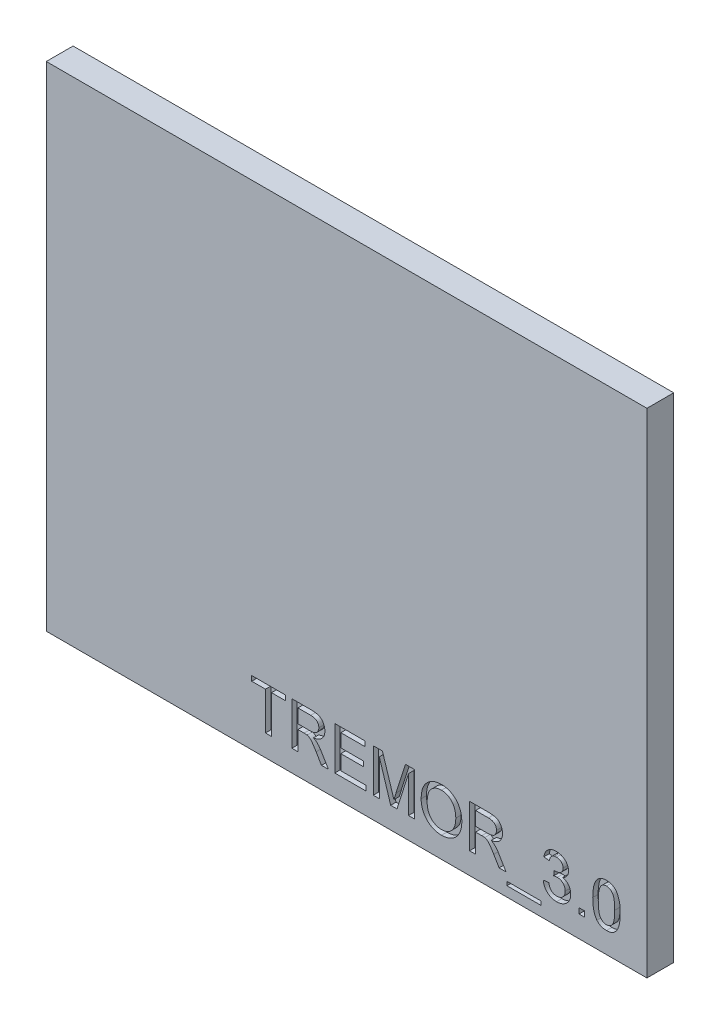
from build123d import *

# Parameters (mm, degrees)
SKETCH_1_W          = 56
SKETCH_1_H          = 46
EXTRUDE_2_DEPTH     = 2.5
SKETCH_3_W          = 3.179487179
SKETCH_3_H          = 0.358974359
SKETCH_3_W_2        = 0.512820512
SKETCH_3_H_2        = 0.512820513
CUT_EXTRUDE_2_DEPTH = 0.5


with BuildPart() as part:
    # Эскиз1 → Бобышка-Вытянуть2 (new body)
    with BuildSketch(Plane.XY):
        Rectangle(SKETCH_1_W, SKETCH_1_H)
    extrude(amount=EXTRUDE_2_DEPTH)

    # Эскиз3 → Вырез-Вытянуть2 (cut)
    with BuildSketch(Plane.XY.offset(2.5)):
        Polygon((-7.564102564, -21), (-7.564102564, -17.461538462), (-8.846153846, -17.461538462), (-8.846153846, -17), (-5.717948718, -17), (-5.717948718, -17.461538462), (-7, -17.461538462), (-7, -21), align=None)
        with BuildLine():
            Line((-5.102564103, -21), (-5.102564103, -17))
            Line((-5.102564103, -17), (-3.366987179, -17))
            add(Edge.make_bspline(
                [(-3.366987179, -17), (-3.326119657, -17.000320214), (-3.247025351, -17.000939951), (-3.132322277, -17.005326982), (-3.025258455, -17.014784271), (-2.925637033, -17.025011011), (-2.833475709, -17.040707691), (-2.748869564, -17.058711428), (-2.67168797, -17.080136147), (-2.60158588, -17.105440392), (-2.536546426, -17.134068355), (-2.476259765, -17.169390639), (-2.418219858, -17.208096331), (-2.364580768, -17.253569742), (-2.31392776, -17.303358919), (-2.26630778, -17.358140389), (-2.222425804, -17.418389546), (-2.168302642, -17.504618584), (-2.110239523, -17.619457505), (-2.061863826, -17.76642644), (-2.030672041, -17.92016131), (-2.027334431, -18.025221285), (-2.025641026, -18.078525641)],
                knots=[0, 0, 0, 0, 0.000122607, 0.000237291, 0.000344225, 0.000445012, 0.000537618, 0.00062453, 0.000704438, 0.000777688, 0.000847982, 0.000917255, 0.00098704, 0.001057009, 0.001127835, 0.001199973, 0.001274496, 0.001351194, 0.001505282, 0.001659088, 0.001814192, 0.001973937, 0.001973937, 0.001973937, 0.001973937], degree=3))
            add(Edge.make_bspline(
                [(-2.025641026, -18.078525641), (-2.026423756, -18.112742284), (-2.027969703, -18.1803225), (-2.039811808, -18.279683507), (-2.061239141, -18.374618953), (-2.088715472, -18.465960267), (-2.126322187, -18.552413288), (-2.169887935, -18.635743845), (-2.223859702, -18.713662625), (-2.284287063, -18.788244481), (-2.353581043, -18.857892068), (-2.432351217, -18.920092674), (-2.519816756, -18.976042242), (-2.616389588, -19.024197105), (-2.720958061, -19.068212935), (-2.834834224, -19.103656602), (-2.95755848, -19.132599074), (-3.04263664, -19.146614136), (-3.086538462, -19.153846154)],
                knots=[0, 0, 0, 0, 0.000102642, 0.000202726, 0.000299545, 0.000394334, 0.000488395, 0.000581956, 0.000675966, 0.000772203, 0.000869657, 0.000970019, 0.001072711, 0.001180575, 0.001293371, 0.00141273, 0.001537894, 0.001671343, 0.001671343, 0.001671343, 0.001671343], degree=3))
            add(Edge.make_bspline(
                [(-3.086538462, -19.153846154), (-3.054334812, -19.170114727), (-2.993178922, -19.201009334), (-2.908507834, -19.249451809), (-2.836735085, -19.298948081), (-2.795153494, -19.33434927), (-2.775641026, -19.350961538)],
                knots=[0, 0, 0, 0, 0.000108229, 0.000205532, 0.000292444, 0.000369288, 0.000369288, 0.000369288, 0.000369288], degree=3))
            add(Edge.make_bspline(
                [(-2.775641026, -19.350961538), (-2.737854029, -19.388003838), (-2.660236854, -19.464091352), (-2.553277014, -19.593690678), (-2.449575777, -19.737954614), (-2.386569456, -19.842214649), (-2.354166667, -19.895833333)],
                knots=[0, 0, 0, 0, 0.00015865, 0.000325878, 0.000503323, 0.000691201, 0.000691201, 0.000691201, 0.000691201], degree=3))
            Line((-2.354166667, -19.895833333), (-1.697916667, -21))
            Line((-1.697916667, -21), (-2.344551282, -21))
            Line((-2.344551282, -21), (-2.842948718, -20.155448718))
            add(Edge.make_bspline(
                [(-2.842948718, -20.155448718), (-2.860868586, -20.125816621), (-2.895594349, -20.068394483), (-2.945754469, -19.984532214), (-2.994934817, -19.907323634), (-3.040548749, -19.834562079), (-3.084447354, -19.767568499), (-3.126206469, -19.706110171), (-3.164676865, -19.649380844), (-3.212327424, -19.583333143), (-3.26778476, -19.510250749), (-3.332499667, -19.434989684), (-3.394127445, -19.374985039), (-3.470023191, -19.316144102), (-3.564031555, -19.261108296), (-3.643940439, -19.235820855), (-3.682692308, -19.223557692)],
                knots=[0, 0, 0, 0, 0.000103889, 0.00020132, 0.000293136, 0.000378497, 0.00045895, 0.0005334, 0.00060141, 0.000664564, 0.000777712, 0.000876533, 0.000962106, 0.001035194, 0.001164397, 0.001286049, 0.001286049, 0.001286049, 0.001286049], degree=3))
            add(Edge.make_bspline(
                [(-3.682692308, -19.223557692), (-3.698951156, -19.220625669), (-3.736070593, -19.213931773), (-3.799099306, -19.209559979), (-3.875466323, -19.204919904), (-3.930810802, -19.205055101), (-3.960737179, -19.205128205)],
                knots=[0, 0, 0, 0, 4.9531e-05, 0.00011308, 0.000189307, 0.000279054, 0.000279054, 0.000279054, 0.000279054], degree=3))
            Line((-3.960737179, -19.205128205), (-4.538461538, -19.205128205))
            Line((-4.538461538, -19.205128205), (-4.538461538, -21))
            Line((-4.538461538, -21), (-5.102564103, -21))
        make_face()
        with BuildLine():
            Line((-4.538461538, -18.743589744), (-3.467147436, -18.743589744))
            add(Edge.make_bspline(
                [(-3.467147436, -18.743589744), (-3.413427689, -18.742749247), (-3.31300366, -18.741178018), (-3.172576543, -18.727761372), (-3.052901394, -18.706441753), (-2.951612407, -18.675344591), (-2.86651367, -18.632171403), (-2.792501681, -18.579556806), (-2.730996786, -18.513651547), (-2.679831068, -18.439291493), (-2.640058905, -18.357461965), (-2.611369163, -18.271512044), (-2.592591229, -18.182164082), (-2.59070121, -18.121355097), (-2.58974359, -18.090544872)],
                knots=[0, 0, 0, 0, 0.000161129, 0.000301216, 0.000422697, 0.000525327, 0.00061778, 0.000707856, 0.000796274, 0.000886733, 0.000977756, 0.001068215, 0.001158102, 0.00125042, 0.00125042, 0.00125042, 0.00125042], degree=3))
            add(Edge.make_bspline(
                [(-2.58974359, -18.090544872), (-2.590488099, -18.068092289), (-2.591946375, -18.024114276), (-2.599591139, -17.959566763), (-2.614454374, -17.898231705), (-2.63408124, -17.83978488), (-2.660306715, -17.784654368), (-2.69146151, -17.732412969), (-2.728638798, -17.683350225), (-2.771223243, -17.637316685), (-2.820117924, -17.595430661), (-2.875967144, -17.559292108), (-2.938330425, -17.528582134), (-3.007280253, -17.504208646), (-3.082599423, -17.484713823), (-3.164716712, -17.471744546), (-3.253256579, -17.46236002), (-3.314609572, -17.461817431), (-3.346153846, -17.461538462)],
                knots=[0, 0, 0, 0, 6.7384e-05, 0.000131985, 0.000194568, 0.000256396, 0.000316615, 0.000377354, 0.000438572, 0.000500939, 0.000565166, 0.000631174, 0.000699977, 0.000773227, 0.000850188, 0.000933046, 0.001022424, 0.001117006, 0.001117006, 0.001117006, 0.001117006], degree=3))
            Line((-3.346153846, -17.461538462), (-4.538461538, -17.461538462))
            Line((-4.538461538, -17.461538462), (-4.538461538, -18.743589744))
        make_face(mode=Mode.SUBTRACT)
        Polygon((-1.102564103, -21), (-1.102564103, -17), (1.717948718, -17), (1.717948718, -17.461538462), (-0.538461538, -17.461538462), (-0.538461538, -18.692307692), (1.564102564, -18.692307692), (1.564102564, -19.153846154), (-0.538461538, -19.153846154), (-0.538461538, -20.538461538), (1.820512821, -20.538461538), (1.820512821, -21), align=None)
        with BuildLine():
            Line((2.487179487, -21), (2.487179487, -17))
            Line((2.487179487, -17), (3.335737179, -17))
            Line((3.335737179, -17), (4.229967949, -19.806891026))
            add(Edge.make_bspline(
                [(4.229967949, -19.806891026), (4.239808996, -19.838688209), (4.25884101, -19.900182111), (4.287063227, -19.988984965), (4.312740714, -20.071507311), (4.335867334, -20.148011825), (4.357692224, -20.218118663), (4.37658914, -20.282403106), (4.394655207, -20.340150808), (4.405242729, -20.376851361), (4.41025641, -20.394230769)],
                knots=[0, 0, 0, 0, 9.9855e-05, 0.000193114, 0.000279538, 0.000359127, 0.000432884, 0.000499809, 0.000560135, 0.000614398, 0.000614398, 0.000614398, 0.000614398], degree=3))
            add(Edge.make_bspline(
                [(4.41025641, -20.394230769), (4.415840487, -20.375259626), (4.427723758, -20.33488782), (4.446988442, -20.271410075), (4.467486613, -20.201164808), (4.492016641, -20.125359419), (4.517586292, -20.042804761), (4.544424968, -19.953569392), (4.575382859, -19.858544221), (4.595955924, -19.792756834), (4.606570513, -19.758814103)],
                knots=[0, 0, 0, 0, 5.9327e-05, 0.000126252, 0.00019901, 0.000278838, 0.000365261, 0.000458282, 0.000558378, 0.000665069, 0.000665069, 0.000665069, 0.000665069], degree=3))
            Line((4.606570513, -19.758814103), (5.491987179, -17))
            Line((5.491987179, -17), (6.333333333, -17))
            Line((6.333333333, -17), (6.333333333, -21))
            Line((6.333333333, -21), (5.769230769, -21))
            Line((5.769230769, -21), (5.769230769, -17.615384615))
            Line((5.769230769, -17.615384615), (4.701923077, -21))
            Line((4.701923077, -21), (4.112179487, -21))
            Line((4.112179487, -21), (3.051282051, -17.615384615))
            Line((3.051282051, -17.615384615), (3.051282051, -21))
            Line((3.051282051, -21), (2.487179487, -21))
        make_face()
        with BuildLine():
            add(Edge.make_bspline(
                [(6.948717949, -19.052884615), (6.950108195, -18.972688063), (6.952817019, -18.816429148), (6.978127021, -18.588896033), (7.019223968, -18.374817135), (7.077975691, -18.174209132), (7.152443668, -17.98675767), (7.242973719, -17.812038293), (7.35228893, -17.6520287), (7.475952289, -17.505205703), (7.614078581, -17.375403412), (7.761143824, -17.260120381), (7.918984399, -17.163960703), (8.086141982, -17.084564511), (8.263326754, -17.023606414), (8.450041232, -16.980930199), (8.646085728, -16.953399893), (8.780086729, -16.950301265), (8.848557692, -16.948717949)],
                knots=[0, 0, 0, 0, 0.000240518, 0.000468637, 0.000685813, 0.00089373, 0.001094751, 0.001290081, 0.001482766, 0.00167493, 0.001864807, 0.002050409, 0.002234557, 0.002418072, 0.002604576, 0.002795443, 0.002991942, 0.003197259, 0.003197259, 0.003197259, 0.003197259], degree=3))
            add(Edge.make_bspline(
                [(8.848557692, -16.948717949), (8.893718998, -16.94950655), (8.983401183, -16.95107257), (9.115988289, -16.962987889), (9.245168372, -16.984254669), (9.370814224, -17.01275454), (9.493267851, -17.050145131), (9.612602383, -17.094283586), (9.727773177, -17.148977346), (9.839546435, -17.210212454), (9.946602755, -17.278706569), (10.047214018, -17.35437188), (10.141139226, -17.436636132), (10.22964005, -17.524147125), (10.309763341, -17.619858234), (10.384819198, -17.720853933), (10.452650846, -17.828925041), (10.513498966, -17.943186098), (10.567903369, -18.061872362), (10.614402437, -18.18547574), (10.654330338, -18.312513522), (10.68775336, -18.443737637), (10.71173528, -18.579103224), (10.730832342, -18.718027005), (10.740883654, -18.86096303), (10.742680104, -18.957518861), (10.743589744, -19.006410256)],
                knots=[0, 0, 0, 0, 0.000135476, 0.000269031, 0.000398917, 0.000527984, 0.000655234, 0.000782779, 0.000909315, 0.001037342, 0.001164925, 0.001290246, 0.00141462, 0.00153927, 0.001663208, 0.001788692, 0.001916521, 0.002045575, 0.002176811, 0.002307921, 0.002441476, 0.002576153, 0.002713829, 0.00285367, 0.002996679, 0.003143368, 0.003143368, 0.003143368, 0.003143368], degree=3))
            add(Edge.make_bspline(
                [(10.743589744, -19.006410256), (10.742756316, -19.056107872), (10.741109736, -19.15429408), (10.729968302, -19.29934515), (10.710377788, -19.440232105), (10.684394308, -19.577375043), (10.649577237, -19.710488463), (10.608202498, -19.839954008), (10.558157415, -19.965000556), (10.501637049, -20.085929494), (10.437684279, -20.201077631), (10.367140035, -20.309639796), (10.289954339, -20.410600475), (10.207299635, -20.505198199), (10.117245715, -20.591741383), (10.020901471, -20.67103927), (9.918637345, -20.743839729), (9.810109783, -20.808171096), (9.697266459, -20.864559837), (9.582340364, -20.914586809), (9.46524613, -20.957251802), (9.345583564, -20.991827538), (9.223679094, -21.017955452), (9.099875772, -21.03752031), (8.973767756, -21.048785823), (8.888910404, -21.050445699), (8.846153846, -21.051282051)],
                knots=[0, 0, 0, 0, 0.000149092, 0.000294558, 0.000436094, 0.000575642, 0.000713045, 0.000848613, 0.000983123, 0.001116825, 0.00124882, 0.001377946, 0.001504873, 0.001629775, 0.001754446, 0.001879099, 0.002003823, 0.002130662, 0.002257158, 0.002382047, 0.002506504, 0.002630767, 0.0027554, 0.002880287, 0.003006587, 0.003134855, 0.003134855, 0.003134855, 0.003134855], degree=3))
            add(Edge.make_bspline(
                [(8.846153846, -21.051282051), (8.800181051, -21.050601878), (8.709120456, -21.049254625), (8.574530444, -21.035806746), (8.443288821, -21.015291538), (8.315777128, -20.985673775), (8.192169605, -20.947035311), (8.072319997, -20.900268536), (7.95580678, -20.845998474), (7.844075689, -20.782671197), (7.737507013, -20.712258071), (7.637133652, -20.635109117), (7.54301111, -20.551935333), (7.456649669, -20.461361953), (7.375252352, -20.366672299), (7.302073791, -20.264346815), (7.234724088, -20.156706135), (7.17519623, -20.04271265), (7.12142172, -19.925753814), (7.076115533, -19.805792216), (7.036300175, -19.68459577), (7.004591274, -19.561417471), (6.979323137, -19.436541465), (6.962332147, -19.310175541), (6.950061124, -19.182131498), (6.949167927, -19.096183714), (6.948717949, -19.052884615)],
                knots=[0, 0, 0, 0, 0.000137879, 0.000273103, 0.000405363, 0.000536171, 0.000665424, 0.000793541, 0.000921869, 0.001050676, 0.001178462, 0.001304753, 0.001430186, 0.001554857, 0.001679924, 0.001804463, 0.001931867, 0.002060544, 0.002189991, 0.00231782, 0.002445024, 0.002572516, 0.002699174, 0.002826998, 0.002954895, 0.003084742, 0.003084742, 0.003084742, 0.003084742], degree=3))
        make_face()
        with BuildLine():
            add(Edge.make_bspline(
                [(7.512820513, -19.059294872), (7.513684973, -19.117043625), (7.51537061, -19.229649619), (7.534655208, -19.39382317), (7.563916506, -19.548729276), (7.604250116, -19.694802796), (7.658468365, -19.830599083), (7.723293301, -19.95742301), (7.800907597, -20.074431521), (7.889598848, -20.181297299), (7.987149056, -20.277297507), (8.091391354, -20.361148581), (8.202349174, -20.431367925), (8.318792352, -20.489348983), (8.441557244, -20.534608486), (8.570276169, -20.566388569), (8.705043701, -20.58626443), (8.796938538, -20.588569422), (8.84375, -20.58974359)],
                knots=[0, 0, 0, 0, 0.000173168, 0.000337665, 0.000495129, 0.000645808, 0.000791478, 0.000933036, 0.001072378, 0.001211803, 0.001348923, 0.001482322, 0.001612362, 0.001742083, 0.001871881, 0.002004032, 0.00213922, 0.002279591, 0.002279591, 0.002279591, 0.002279591], degree=3))
            add(Edge.make_bspline(
                [(8.84375, -20.58974359), (8.891354918, -20.588552055), (8.984565213, -20.586219033), (9.121364549, -20.56669014), (9.251339232, -20.533443034), (9.375777543, -20.489183603), (9.492429758, -20.429352398), (9.604024039, -20.359290384), (9.707518311, -20.27367661), (9.805453067, -20.177506616), (9.893293946, -20.068191756), (9.971234233, -19.948424801), (10.034547437, -19.816409553), (10.089209843, -19.675054127), (10.129236807, -19.521686851), (10.158819186, -19.358051203), (10.176646155, -19.183620818), (10.178523426, -19.063877596), (10.179487179, -19.002403846)],
                knots=[0, 0, 0, 0, 0.000142772, 0.000279548, 0.000413448, 0.000544751, 0.00067483, 0.000805976, 0.000939254, 0.001076937, 0.001217095, 0.001359121, 0.001504613, 0.001655512, 0.001813144, 0.001979273, 0.002154042, 0.002338423, 0.002338423, 0.002338423, 0.002338423], degree=3))
            add(Edge.make_bspline(
                [(10.179487179, -19.002403846), (10.179146589, -18.962855637), (10.178478475, -18.885276363), (10.169630401, -18.770923625), (10.158217521, -18.660127911), (10.140841233, -18.553032189), (10.116894504, -18.450079966), (10.090365595, -18.350487464), (10.057192122, -18.255112917), (10.019552193, -18.163582302), (9.97743375, -18.07636552), (9.929929749, -17.994197843), (9.877592282, -17.917398722), (9.821833476, -17.844512122), (9.759565724, -17.778359053), (9.693787254, -17.716145179), (9.623003911, -17.659155853), (9.547922087, -17.607376188), (9.469606915, -17.560766328), (9.388219841, -17.520874336), (9.305057476, -17.485834233), (9.218727802, -17.458974524), (9.130422863, -17.437311773), (9.039785685, -17.420856897), (8.946479846, -17.412335797), (8.883561888, -17.410954516), (8.851762821, -17.41025641)],
                knots=[0, 0, 0, 0, 0.000118614, 0.000232678, 0.000343906, 0.000452715, 0.000557879, 0.000660905, 0.000761759, 0.000860564, 0.000957681, 0.0010521, 0.001144996, 0.001236357, 0.001327075, 0.001417208, 0.001507809, 0.001599384, 0.001690631, 0.001780935, 0.00187111, 0.001961072, 0.002051829, 0.002143781, 0.002237147, 0.002332553, 0.002332553, 0.002332553, 0.002332553], degree=3))
            add(Edge.make_bspline(
                [(8.851762821, -17.41025641), (8.806819177, -17.411148973), (8.718140361, -17.4129101), (8.587594586, -17.432487753), (8.461734305, -17.461739442), (8.340364196, -17.502634862), (8.224522319, -17.556786824), (8.113608506, -17.623196796), (8.006638236, -17.700056537), (7.905298277, -17.789238719), (7.810827268, -17.891687275), (7.730961508, -18.012470984), (7.663648464, -18.148706484), (7.607443312, -18.30004845), (7.564588538, -18.467668926), (7.53497053, -18.650846562), (7.516270323, -18.849774382), (7.513999848, -18.987669243), (7.512820513, -19.059294872)],
                knots=[0, 0, 0, 0, 0.000134732, 0.000265842, 0.000395089, 0.000522039, 0.000649301, 0.000777926, 0.000909359, 0.00104391, 0.001182325, 0.001326112, 0.001476617, 0.001637361, 0.001809553, 0.001994765, 0.002193538, 0.002408378, 0.002408378, 0.002408378, 0.002408378], degree=3))
        make_face(mode=Mode.SUBTRACT)
        with BuildLine():
            Line((11.461538462, -21), (11.461538462, -17))
            Line((11.461538462, -17), (13.197115385, -17))
            add(Edge.make_bspline(
                [(13.197115385, -17), (13.237982907, -17.000320214), (13.317077213, -17.000939951), (13.431780288, -17.005326982), (13.538844109, -17.014784271), (13.638465531, -17.025011011), (13.730626855, -17.040707691), (13.815233, -17.058711428), (13.892414594, -17.080136147), (13.962516684, -17.105440392), (14.027556138, -17.134068355), (14.087842799, -17.169390639), (14.145882706, -17.208096331), (14.199521796, -17.253569742), (14.250174804, -17.303358919), (14.297794784, -17.358140389), (14.34167676, -17.418389546), (14.395799922, -17.504618584), (14.453863041, -17.619457505), (14.502238738, -17.76642644), (14.533430523, -17.92016131), (14.536768133, -18.025221285), (14.538461538, -18.078525641)],
                knots=[0, 0, 0, 0, 0.000122607, 0.000237291, 0.000344225, 0.000445012, 0.000537618, 0.00062453, 0.000704438, 0.000777688, 0.000847982, 0.000917255, 0.00098704, 0.001057009, 0.001127835, 0.001199973, 0.001274496, 0.001351194, 0.001505282, 0.001659088, 0.001814192, 0.001973937, 0.001973937, 0.001973937, 0.001973937], degree=3))
            add(Edge.make_bspline(
                [(14.538461538, -18.078525641), (14.537678808, -18.112742284), (14.536132862, -18.1803225), (14.524290756, -18.279683507), (14.502863423, -18.374618953), (14.475387092, -18.465960267), (14.437780377, -18.552413288), (14.394214629, -18.635743845), (14.340242862, -18.713662625), (14.279815501, -18.788244481), (14.210521522, -18.857892068), (14.131751347, -18.920092674), (14.044285808, -18.976042242), (13.947712976, -19.024197105), (13.843144503, -19.068212935), (13.72926834, -19.103656602), (13.606544084, -19.132599074), (13.521465925, -19.146614136), (13.477564103, -19.153846154)],
                knots=[0, 0, 0, 0, 0.000102642, 0.000202726, 0.000299545, 0.000394334, 0.000488395, 0.000581956, 0.000675966, 0.000772203, 0.000869657, 0.000970019, 0.001072711, 0.001180575, 0.001293371, 0.00141273, 0.001537894, 0.001671343, 0.001671343, 0.001671343, 0.001671343], degree=3))
            add(Edge.make_bspline(
                [(13.477564103, -19.153846154), (13.509767752, -19.170114727), (13.570923642, -19.201009334), (13.65559473, -19.249451809), (13.72736748, -19.298948081), (13.768949071, -19.33434927), (13.788461538, -19.350961538)],
                knots=[0, 0, 0, 0, 0.000108229, 0.000205532, 0.000292444, 0.000369288, 0.000369288, 0.000369288, 0.000369288], degree=3))
            add(Edge.make_bspline(
                [(13.788461538, -19.350961538), (13.826248535, -19.388003838), (13.90386571, -19.464091352), (14.01082555, -19.593690678), (14.114526787, -19.737954614), (14.177533108, -19.842214649), (14.209935897, -19.895833333)],
                knots=[0, 0, 0, 0, 0.00015865, 0.000325878, 0.000503323, 0.000691201, 0.000691201, 0.000691201, 0.000691201], degree=3))
            Line((14.209935897, -19.895833333), (14.866185897, -21))
            Line((14.866185897, -21), (14.219551282, -21))
            Line((14.219551282, -21), (13.721153846, -20.155448718))
            add(Edge.make_bspline(
                [(13.721153846, -20.155448718), (13.703233978, -20.125816621), (13.668508215, -20.068394483), (13.618348095, -19.984532214), (13.569167747, -19.907323634), (13.523553815, -19.834562079), (13.47965521, -19.767568499), (13.437896095, -19.706110171), (13.399425699, -19.649380844), (13.35177514, -19.583333143), (13.296317804, -19.510250749), (13.231602897, -19.434989684), (13.169975119, -19.374985039), (13.094079373, -19.316144102), (13.000071009, -19.261108296), (12.920162126, -19.235820855), (12.881410256, -19.223557692)],
                knots=[0, 0, 0, 0, 0.000103889, 0.00020132, 0.000293136, 0.000378497, 0.00045895, 0.0005334, 0.00060141, 0.000664564, 0.000777712, 0.000876533, 0.000962106, 0.001035194, 0.001164397, 0.001286049, 0.001286049, 0.001286049, 0.001286049], degree=3))
            add(Edge.make_bspline(
                [(12.881410256, -19.223557692), (12.865151408, -19.220625669), (12.828031971, -19.213931773), (12.765003259, -19.209559979), (12.688636241, -19.204919904), (12.633291762, -19.205055101), (12.603365385, -19.205128205)],
                knots=[0, 0, 0, 0, 4.9531e-05, 0.00011308, 0.000189307, 0.000279054, 0.000279054, 0.000279054, 0.000279054], degree=3))
            Line((12.603365385, -19.205128205), (12.025641026, -19.205128205))
            Line((12.025641026, -19.205128205), (12.025641026, -21))
            Line((12.025641026, -21), (11.461538462, -21))
        make_face()
        with BuildLine():
            Line((12.025641026, -18.743589744), (13.096955128, -18.743589744))
            add(Edge.make_bspline(
                [(13.096955128, -18.743589744), (13.150674875, -18.742749247), (13.251098904, -18.741178018), (13.391526021, -18.727761372), (13.51120117, -18.706441753), (13.612490157, -18.675344591), (13.697588895, -18.632171403), (13.771600883, -18.579556806), (13.833105778, -18.513651547), (13.884271497, -18.439291493), (13.924043659, -18.357461965), (13.952733401, -18.271512044), (13.971511335, -18.182164082), (13.973401354, -18.121355097), (13.974358974, -18.090544872)],
                knots=[0, 0, 0, 0, 0.000161129, 0.000301216, 0.000422697, 0.000525327, 0.00061778, 0.000707856, 0.000796274, 0.000886733, 0.000977756, 0.001068215, 0.001158102, 0.00125042, 0.00125042, 0.00125042, 0.00125042], degree=3))
            add(Edge.make_bspline(
                [(13.974358974, -18.090544872), (13.973614465, -18.068092289), (13.972156189, -18.024114276), (13.964511425, -17.959566763), (13.94964819, -17.898231705), (13.930021324, -17.83978488), (13.903795849, -17.784654368), (13.872641054, -17.732412969), (13.835463766, -17.683350225), (13.792879321, -17.637316685), (13.74398464, -17.595430661), (13.68813542, -17.559292108), (13.625772139, -17.528582134), (13.556822311, -17.504208646), (13.481503141, -17.484713823), (13.399385852, -17.471744546), (13.310845985, -17.46236002), (13.249492992, -17.461817431), (13.217948718, -17.461538462)],
                knots=[0, 0, 0, 0, 6.7384e-05, 0.000131985, 0.000194568, 0.000256396, 0.000316615, 0.000377354, 0.000438572, 0.000500939, 0.000565166, 0.000631174, 0.000699977, 0.000773227, 0.000850188, 0.000933046, 0.001022424, 0.001117006, 0.001117006, 0.001117006, 0.001117006], degree=3))
            Line((13.217948718, -17.461538462), (12.025641026, -17.461538462))
            Line((12.025641026, -17.461538462), (12.025641026, -18.743589744))
        make_face(mode=Mode.SUBTRACT)
        with Locations((16.538461539, -21.897435898)):
            Rectangle(SKETCH_3_W, SKETCH_3_H)
        with BuildLine():
            Line((18.333333333, -19.923076923), (18.846153846, -19.871794872))
            add(Edge.make_bspline(
                [(18.846153846, -19.871794872), (18.852990358, -19.902608165), (18.866218501, -19.962229603), (18.891671063, -20.047643506), (18.918554558, -20.126926707), (18.951881871, -20.198305832), (18.984402084, -20.264699992), (19.022618259, -20.323365841), (19.063452984, -20.375834051), (19.107661156, -20.421909794), (19.155752195, -20.461586636), (19.20708494, -20.496306013), (19.262745033, -20.525301367), (19.322306325, -20.548258621), (19.385267168, -20.566842713), (19.451969722, -20.580488675), (19.5227667, -20.588617745), (19.571292281, -20.589362184), (19.596153846, -20.58974359)],
                knots=[0, 0, 0, 0, 9.4653e-05, 0.000183147, 0.000267285, 0.000345471, 0.000419293, 0.000488862, 0.000555063, 0.000618532, 0.000679985, 0.000741767, 0.000804129, 0.000867814, 0.000932975, 0.001000862, 0.001071828, 0.001146386, 0.001146386, 0.001146386, 0.001146386], degree=3))
            add(Edge.make_bspline(
                [(19.596153846, -20.58974359), (19.62531558, -20.589327814), (19.682268493, -20.588515804), (19.765258282, -20.576332543), (19.844237703, -20.559603765), (19.918079925, -20.533372085), (19.987813163, -20.501312121), (20.053040142, -20.461692808), (20.114207338, -20.415169819), (20.170108272, -20.361426702), (20.220100338, -20.30230756), (20.264625296, -20.239862658), (20.301441455, -20.173559172), (20.332471933, -20.104331006), (20.355376484, -20.031059466), (20.372144464, -19.954658211), (20.383102426, -19.874781723), (20.384104144, -19.820282428), (20.384615385, -19.792467949)],
                knots=[0, 0, 0, 0, 8.7399e-05, 0.000170689, 0.000251169, 0.000329219, 0.000405219, 0.000481074, 0.00055768, 0.000635321, 0.000713194, 0.00078967, 0.000865007, 0.000940345, 0.001016874, 0.001094834, 0.001174842, 0.001258237, 0.001258237, 0.001258237, 0.001258237], degree=3))
            add(Edge.make_bspline(
                [(20.384615385, -19.792467949), (20.384014526, -19.765998224), (20.382838995, -19.714212317), (20.373175178, -19.638201716), (20.356312031, -19.566047154), (20.332935677, -19.497331047), (20.303065495, -19.432154273), (20.267162417, -19.369977884), (20.223250008, -19.312164477), (20.17382272, -19.258093084), (20.119911969, -19.208277818), (20.060914933, -19.165903522), (19.998827877, -19.129333124), (19.932910868, -19.099803958), (19.863437594, -19.07636649), (19.790474285, -19.059521522), (19.713670149, -19.049853511), (19.661352126, -19.048677774), (19.634615385, -19.048076923)],
                knots=[0, 0, 0, 0, 7.9392e-05, 0.000155323, 0.000229376, 0.00030134, 0.000372694, 0.000444157, 0.000516272, 0.000590008, 0.000663743, 0.000736027, 0.00080749, 0.000879574, 0.000952297, 0.00102713, 0.001103857, 0.001184049, 0.001184049, 0.001184049, 0.001184049], degree=3))
            add(Edge.make_bspline(
                [(19.634615385, -19.048076923), (19.611075308, -19.048700574), (19.561117777, -19.050024106), (19.482268074, -19.061710395), (19.394928674, -19.078073941), (19.334574655, -19.094132334), (19.302884615, -19.102564103)],
                knots=[0, 0, 0, 0, 7.0586e-05, 0.000149799, 0.000238745, 0.000337081, 0.000337081, 0.000337081, 0.000337081], degree=3))
            Line((19.302884615, -19.102564103), (19.355769231, -18.641025641))
            add(Edge.make_bspline(
                [(19.355769231, -18.641025641), (19.369644917, -18.642541874), (19.394158478, -18.645220537), (19.418795659, -18.646206673), (19.429487179, -18.646634615)],
                knots=[0, 0, 0, 0, 4.1859e-05, 7.395e-05, 7.395e-05, 7.395e-05, 7.395e-05], degree=3))
            add(Edge.make_bspline(
                [(19.429487179, -18.646634615), (19.476649684, -18.644833969), (19.569167694, -18.641301667), (19.704041018, -18.611951196), (19.831861372, -18.565739827), (19.930610852, -18.51060296), (20.00384013, -18.458743741), (20.05001704, -18.411985299), (20.091647907, -18.362365146), (20.122707936, -18.305449034), (20.149541885, -18.24497429), (20.166158747, -18.178558653), (20.178277122, -18.107816516), (20.179076585, -18.058818589), (20.179487179, -18.033653846)],
                knots=[0, 0, 0, 0, 0.000141353, 0.00027729, 0.000412153, 0.000547729, 0.00061536, 0.000680521, 0.000744342, 0.000808944, 0.000874281, 0.00094231, 0.00101371, 0.001089098, 0.001089098, 0.001089098, 0.001089098], degree=3))
            add(Edge.make_bspline(
                [(20.179487179, -18.033653846), (20.179108231, -18.013327435), (20.178367114, -17.973574708), (20.170110739, -17.915293013), (20.156455709, -17.860069312), (20.137999577, -17.807313968), (20.113810983, -17.757303464), (20.083815229, -17.710099022), (20.049544061, -17.664743062), (20.00908816, -17.623579285), (19.965763401, -17.58493261), (19.917989906, -17.552384185), (19.868041338, -17.523469693), (19.814156123, -17.501620362), (19.757664561, -17.483656649), (19.698083755, -17.471068406), (19.635391958, -17.462614557), (19.59244357, -17.461902209), (19.570512821, -17.461538462)],
                knots=[0, 0, 0, 0, 6.0945e-05, 0.000119191, 0.000176133, 0.000231381, 0.00028657, 0.000342373, 0.000398947, 0.000456751, 0.000515244, 0.000572814, 0.000629863, 0.000688048, 0.000746843, 0.000807508, 0.00087052, 0.000936269, 0.000936269, 0.000936269, 0.000936269], degree=3))
            add(Edge.make_bspline(
                [(19.570512821, -17.461538462), (19.527594897, -17.463211902), (19.444714027, -17.466443564), (19.326052177, -17.496343139), (19.218523117, -17.544724543), (19.138913785, -17.601462422), (19.082384159, -17.655707044), (19.04377143, -17.701685617), (19.009234532, -17.75245937), (18.978675582, -17.808010205), (18.952507438, -17.868561527), (18.928917583, -17.933363196), (18.910656847, -18.003452687), (18.901917587, -18.052017794), (18.897435897, -18.076923077)],
                knots=[0, 0, 0, 0, 0.000128565, 0.000248278, 0.000364462, 0.000480523, 0.00053946, 0.00059917, 0.000660288, 0.000723407, 0.000789063, 0.000858001, 0.000930108, 0.00100601, 0.00100601, 0.00100601, 0.00100601], degree=3))
            Line((18.897435897, -18.076923077), (18.384615385, -18.025641026))
            add(Edge.make_bspline(
                [(18.384615385, -18.025641026), (18.392637428, -17.985989186), (18.408373298, -17.90820898), (18.44043239, -17.795873168), (18.479528056, -17.690421831), (18.526468972, -17.59233844), (18.579037501, -17.500449171), (18.639679113, -17.415843971), (18.706972064, -17.338019852), (18.781035885, -17.267214189), (18.860865116, -17.203976812), (18.946057678, -17.149426277), (19.035914428, -17.103186838), (19.130519494, -17.065909669), (19.229797974, -17.035597682), (19.334032308, -17.015515915), (19.442750695, -17.001931613), (19.516783487, -17.000651792), (19.554487179, -17)],
                knots=[0, 0, 0, 0, 0.00012133, 0.000237999, 0.000350069, 0.000458311, 0.000563861, 0.000667254, 0.000770072, 0.000872083, 0.000974199, 0.00107511, 0.001175093, 0.001276869, 0.001379789, 0.001486019, 0.001594949, 0.001708001, 0.001708001, 0.001708001, 0.001708001], degree=3))
            add(Edge.make_bspline(
                [(19.554487179, -17), (19.606678066, -17.001692422), (19.709302222, -17.005020271), (19.860033192, -17.031450449), (20.004206572, -17.074822898), (20.140662208, -17.134944847), (20.267052451, -17.208412283), (20.378897399, -17.29645853), (20.474701836, -17.397560407), (20.552604973, -17.51061258), (20.614293329, -17.630979359), (20.659940858, -17.755925298), (20.687215941, -17.885306561), (20.69060699, -17.972897644), (20.692307692, -18.016826923)],
                knots=[0, 0, 0, 0, 0.000156498, 0.000307726, 0.00045754, 0.000607159, 0.000754065, 0.000894975, 0.001032714, 0.001170303, 0.001305407, 0.001437463, 0.001568366, 0.001700072, 0.001700072, 0.001700072, 0.001700072], degree=3))
            add(Edge.make_bspline(
                [(20.692307692, -18.016826923), (20.69058352, -18.058353136), (20.687179226, -18.140344654), (20.660970177, -18.260230778), (20.616682099, -18.3738094), (20.556821247, -18.481479015), (20.47919641, -18.580911181), (20.384020798, -18.669514304), (20.272816972, -18.748136183), (20.18947911, -18.789058001), (20.146634615, -18.810096154)],
                knots=[0, 0, 0, 0, 0.000124511, 0.000245841, 0.000366076, 0.000489122, 0.000614145, 0.000742823, 0.000877983, 0.001020991, 0.001020991, 0.001020991, 0.001020991], degree=3))
            add(Edge.make_bspline(
                [(20.146634615, -18.810096154), (20.175358991, -18.81734849), (20.231621657, -18.831553701), (20.312427607, -18.860986496), (20.38839427, -18.895444894), (20.460532717, -18.934473085), (20.52674863, -18.980630248), (20.589324416, -19.031097872), (20.645894563, -19.088306514), (20.698098011, -19.150217158), (20.745596738, -19.216181896), (20.785567383, -19.287483892), (20.820060888, -19.362248742), (20.84947367, -19.441018713), (20.870609629, -19.52440118), (20.885722507, -19.611750179), (20.895695774, -19.70276223), (20.896850171, -19.764930818), (20.897435897, -19.796474359)],
                knots=[0, 0, 0, 0, 8.883e-05, 0.000173993, 0.000257549, 0.000338957, 0.000419636, 0.000499355, 0.000579811, 0.000660554, 0.000742151, 0.000823251, 0.00090535, 0.000989006, 0.001075102, 0.00116297, 0.00125482, 0.001349426, 0.001349426, 0.001349426, 0.001349426], degree=3))
            add(Edge.make_bspline(
                [(20.897435897, -19.796474359), (20.896459866, -19.839538881), (20.89454165, -19.924174485), (20.876356907, -20.048506113), (20.846638954, -20.167632529), (20.805513294, -20.281958261), (20.753400576, -20.391949895), (20.688007709, -20.496055261), (20.61127279, -20.595120595), (20.524395462, -20.688197383), (20.429213034, -20.773737816), (20.32584856, -20.847807652), (20.216347096, -20.910708923), (20.100530448, -20.9620046), (19.978705642, -21.002305264), (19.850751488, -21.031194068), (19.716272035, -21.048172315), (19.624514685, -21.050231831), (19.577724359, -21.051282051)],
                knots=[0, 0, 0, 0, 0.000129128, 0.000253779, 0.000376018, 0.000496916, 0.000617697, 0.000740429, 0.000864961, 0.000993091, 0.001121918, 0.001248226, 0.001373851, 0.001500119, 0.001627573, 0.001758202, 0.00189307, 0.002033406, 0.002033406, 0.002033406, 0.002033406], degree=3))
            add(Edge.make_bspline(
                [(19.577724359, -21.051282051), (19.535733925, -21.050491122), (19.453069027, -21.048934051), (19.332064686, -21.032712025), (19.216136237, -21.009691108), (19.106200377, -20.974201597), (19.000980105, -20.930922712), (18.902257468, -20.875553908), (18.80825736, -20.811992666), (18.720744514, -20.738423024), (18.640204936, -20.657221371), (18.568353999, -20.569588749), (18.50665511, -20.475719726), (18.452255446, -20.377018765), (18.408286448, -20.271625301), (18.374049622, -20.160444207), (18.347943582, -20.043888107), (18.338256405, -19.963785481), (18.333333333, -19.923076923)],
                knots=[0, 0, 0, 0, 0.000125893, 0.000247841, 0.000365703, 0.000479994, 0.000593838, 0.000706455, 0.000818912, 0.000933817, 0.001048836, 0.001161592, 0.001273155, 0.001385386, 0.00149923, 0.001615051, 0.001734032, 0.001856984, 0.001856984, 0.001856984, 0.001856984], degree=3))
        make_face()
        with Locations((21.923076923, -20.743589744)):
            Rectangle(SKETCH_3_W_2, SKETCH_3_H_2)
        with BuildLine():
            add(Edge.make_bspline(
                [(22.948717949, -19.02724359), (22.949234615, -18.970079918), (22.950246548, -18.858120358), (22.956523238, -18.694303408), (22.967481829, -18.538733234), (22.983839989, -18.39154494), (23.003211115, -18.252406296), (23.0283937, -18.121515864), (23.056727771, -17.998579972), (23.09072357, -17.883726761), (23.128073825, -17.775968701), (23.17044888, -17.675478661), (23.218126566, -17.582363185), (23.26876382, -17.495656612), (23.325026291, -17.416707586), (23.38351809, -17.343300475), (23.44849005, -17.278127405), (23.517240499, -17.219511464), (23.590781805, -17.167786313), (23.66872486, -17.123153747), (23.750769762, -17.083746408), (23.838480196, -17.054080575), (23.93003531, -17.029896631), (24.026139847, -17.012106629), (24.126899713, -17.001618823), (24.195754918, -17.000545704), (24.230769231, -17)],
                knots=[0, 0, 0, 0, 0.000171491, 0.000335879, 0.000491732, 0.00063924, 0.000780095, 0.000913045, 0.001038989, 0.001158412, 0.001272197, 0.001380988, 0.001485269, 0.001585861, 0.001681898, 0.001775881, 0.001867104, 0.001957492, 0.002046637, 0.002136384, 0.002226712, 0.002319207, 0.002413663, 0.002510632, 0.002612129, 0.002717146, 0.002717146, 0.002717146, 0.002717146], degree=3))
            add(Edge.make_bspline(
                [(24.230769231, -17), (24.282139782, -17.001510258), (24.383059289, -17.00447722), (24.530402292, -17.028675224), (24.669263575, -17.070069641), (24.799552922, -17.125912494), (24.919043056, -17.196843665), (25.025752782, -17.283071311), (25.118531064, -17.383690057), (25.196365369, -17.499892204), (25.264400322, -17.628472119), (25.324841079, -17.770006917), (25.379477769, -17.924337993), (25.418249153, -18.06248585), (25.44590475, -18.181739983), (25.464210558, -18.280097418), (25.479408048, -18.386225644), (25.491051379, -18.499867908), (25.500604458, -18.620896751), (25.507981863, -18.749387527), (25.511726651, -18.885661377), (25.512449057, -18.979164781), (25.512820513, -19.02724359)],
                knots=[0, 0, 0, 0, 0.000154055, 0.000302647, 0.000446398, 0.000587806, 0.000726874, 0.000861901, 0.000998001, 0.001135796, 0.001280262, 0.001433875, 0.001597085, 0.001771098, 0.001864008, 0.001964274, 0.002071134, 0.002185549, 0.002306924, 0.002435332, 0.002571608, 0.002715848, 0.002715848, 0.002715848, 0.002715848], degree=3))
            add(Edge.make_bspline(
                [(25.512820513, -19.02724359), (25.512294168, -19.084138755), (25.51126585, -19.19529466), (25.505157347, -19.357798074), (25.493538424, -19.512194547), (25.479241127, -19.658837757), (25.457612311, -19.797336234), (25.43430609, -19.928278423), (25.405482051, -20.051069731), (25.371851166, -20.165763973), (25.333975152, -20.272967612), (25.292438241, -20.373490833), (25.246432125, -20.467264948), (25.194587486, -20.553375331), (25.139276452, -20.632964952), (25.080093929, -20.706332371), (25.015785178, -20.772421619), (24.946415181, -20.830861742), (24.873390227, -20.883504165), (24.795257678, -20.92857739), (24.712359506, -20.965919774), (24.625249586, -20.997845657), (24.533044063, -21.021239071), (24.43647006, -21.039146364), (24.335171749, -21.049691475), (24.266050217, -21.050744544), (24.230769231, -21.051282051)],
                knots=[0, 0, 0, 0, 0.00017069, 0.000333477, 0.000487731, 0.000635154, 0.000775333, 0.000908135, 0.001034079, 0.001153503, 0.001266532, 0.001375013, 0.00147965, 0.001579554, 0.001676247, 0.001770229, 0.001862024, 0.001952413, 0.002042021, 0.002131768, 0.002222486, 0.002314494, 0.002409725, 0.002507482, 0.002608979, 0.002714797, 0.002714797, 0.002714797, 0.002714797], degree=3))
            add(Edge.make_bspline(
                [(24.230769231, -21.051282051), (24.184511767, -21.049962555), (24.094322443, -21.047389899), (23.962607586, -21.029910292), (23.838986167, -20.999145362), (23.722415511, -20.957885252), (23.614205903, -20.90269748), (23.513840685, -20.835550779), (23.419303091, -20.758007387), (23.364881504, -20.696827431), (23.337339744, -20.665865385)],
                knots=[0, 0, 0, 0, 0.00013877, 0.000270563, 0.000397662, 0.000520339, 0.000640745, 0.000760975, 0.000882138, 0.001006285, 0.001006285, 0.001006285, 0.001006285], degree=3))
            add(Edge.make_bspline(
                [(23.337339744, -20.665865385), (23.305638543, -20.620135938), (23.240269312, -20.525839863), (23.163760294, -20.365056307), (23.095512896, -20.188056186), (23.041951201, -19.991366779), (22.999999042, -19.776553511), (22.969699109, -19.543194874), (22.952552329, -19.291391684), (22.950024929, -19.117280617), (22.948717949, -19.02724359)],
                knots=[0, 0, 0, 0, 0.000166682, 0.000343706, 0.0005324, 0.000735364, 0.000954266, 0.001188624, 0.001440844, 0.001710952, 0.001710952, 0.001710952, 0.001710952], degree=3))
        make_face()
        with BuildLine():
            add(Edge.make_bspline(
                [(23.461538462, -19.025641026), (23.462047652, -19.102575575), (23.463022354, -19.249845318), (23.473205627, -19.460245556), (23.490735711, -19.65005529), (23.513911629, -19.819011716), (23.544513223, -19.967343382), (23.582937144, -20.094672293), (23.626250042, -20.202526684), (23.679848932, -20.289569783), (23.738533797, -20.360522607), (23.79912191, -20.42154433), (23.863038699, -20.473411397), (23.929867114, -20.516657953), (24.000644048, -20.549401405), (24.074595566, -20.573133931), (24.151737759, -20.586791636), (24.204275098, -20.588753991), (24.230769231, -20.58974359)],
                knots=[0, 0, 0, 0, 0.000230791, 0.000441786, 0.000631708, 0.000802479, 0.000953191, 0.001085506, 0.001201138, 0.001300772, 0.001390751, 0.001476873, 0.00155834, 0.001637249, 0.00171504, 0.001791569, 0.001869689, 0.001949162, 0.001949162, 0.001949162, 0.001949162], degree=3))
            add(Edge.make_bspline(
                [(24.230769231, -20.58974359), (24.257256729, -20.588732368), (24.309780912, -20.586727135), (24.387101349, -20.573370596), (24.460765139, -20.548416336), (24.531436544, -20.515788534), (24.598750689, -20.473527696), (24.662353563, -20.421464716), (24.723260842, -20.360479225), (24.781682096, -20.288701704), (24.834872638, -20.201256176), (24.878998032, -20.093489643), (24.916823138, -19.965937741), (24.947592649, -19.81768165), (24.97086417, -19.648992356), (24.988288266, -19.459709068), (24.998539688, -19.249579547), (24.999498305, -19.102575922), (25, -19.025641026)],
                knots=[0, 0, 0, 0, 7.9472e-05, 0.000157592, 0.000234369, 0.00031216, 0.00039064, 0.000472107, 0.000558229, 0.000648831, 0.000749148, 0.000864042, 0.000997125, 0.001147836, 0.001317814, 0.001507736, 0.00171793, 0.001948722, 0.001948722, 0.001948722, 0.001948722], degree=3))
            add(Edge.make_bspline(
                [(25, -19.025641026), (24.999514368, -18.950306896), (24.998583915, -18.805969554), (24.988068095, -18.599622682), (24.971588861, -18.412998827), (24.949047885, -18.245925939), (24.919090933, -18.098585398), (24.882757237, -17.970663537), (24.839460205, -17.862433169), (24.787980189, -17.772807118), (24.73067263, -17.699289441), (24.670809452, -17.635653496), (24.60689407, -17.581533197), (24.537794095, -17.538117095), (24.465736749, -17.503090599), (24.389066338, -17.478984472), (24.308536471, -17.464174422), (24.253269868, -17.462427154), (24.225160256, -17.461538462)],
                knots=[0, 0, 0, 0, 0.000225984, 0.000432977, 0.000619635, 0.000787914, 0.000938461, 0.00107032, 0.001186384, 0.001287263, 0.001379257, 0.001465409, 0.001549023, 0.001629714, 0.001709637, 0.001788701, 0.001870117, 0.001954389, 0.001954389, 0.001954389, 0.001954389], degree=3))
            add(Edge.make_bspline(
                [(24.225160256, -17.461538462), (24.198667787, -17.462233784), (24.146428033, -17.463604872), (24.069942191, -17.476691886), (23.997457457, -17.498576292), (23.928143391, -17.528220845), (23.86373038, -17.568116557), (23.801663966, -17.614697641), (23.744851098, -17.671451493), (23.710616163, -17.713879785), (23.693108974, -17.735576923)],
                knots=[0, 0, 0, 0, 7.9428e-05, 0.000156622, 0.000231913, 0.000306194, 0.00038205, 0.000458655, 0.000538547, 0.000622161, 0.000622161, 0.000622161, 0.000622161], degree=3))
            add(Edge.make_bspline(
                [(23.693108974, -17.735576923), (23.674048987, -17.767443298), (23.633798307, -17.834738374), (23.588760136, -17.951699987), (23.548975196, -18.085364848), (23.516219001, -18.237789488), (23.492522191, -18.408712437), (23.473814476, -18.5979352), (23.464096514, -18.805721956), (23.462414672, -18.950312123), (23.461538462, -19.025641026)],
                knots=[0, 0, 0, 0, 0.000111217, 0.000234866, 0.000374549, 0.000529514, 0.000701985, 0.000891984, 0.001099777, 0.001325774, 0.001325774, 0.001325774, 0.001325774], degree=3))
        make_face(mode=Mode.SUBTRACT)
    extrude(amount=-CUT_EXTRUDE_2_DEPTH, mode=Mode.SUBTRACT)


solid = part.part
